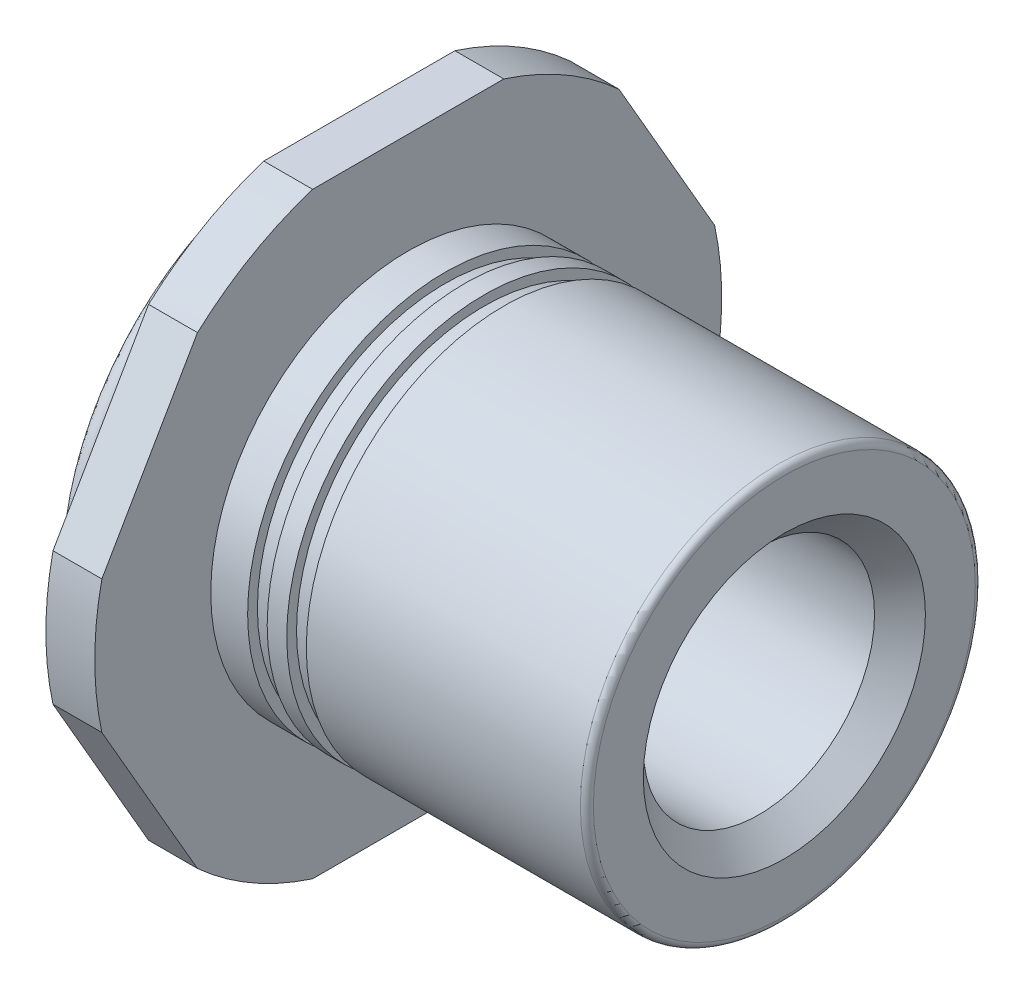
from build123d import *

# Parameters (mm, degrees)
BOSS_EXTRUDE1_DEPTH      = 0.52
M2_CLEARANCE_HOLE1_D     = 2.459
M2_CLEARANCE_HOLE1_DEPTH = 5.04
CHAMFER1_SIZE            = 0.2705
FILLET1_R                = 0.069333333


with BuildPart() as part:
    # Sketch1 → Boss-Extrude1 (new body)
    with BuildSketch(Plane(origin=(-0.52, 0, 0), x_dir=(0, -1, 0), z_dir=(-1, 0, 0))):
        with BuildLine():
            Line((-3.175, 1.016495973), (-3.175, -1.016495973))
            ThreePointArc((-3.175, -1.016495973), (-2.88711219, -1.666875), (-2.467811335, -2.241382671))
            Line((-2.467811335, -2.241382671), (-0.707188665, -3.257878643))
            ThreePointArc((-0.707188665, -3.257878643), (0, -3.33375), (0.707188665, -3.257878643))
            Line((0.707188665, -3.257878643), (2.467811335, -2.241382671))
            ThreePointArc((2.467811335, -2.241382671), (2.88711219, -1.666875), (3.175, -1.016495973))
            Line((3.175, -1.016495973), (3.175, 1.016495973))
            ThreePointArc((3.175, 1.016495973), (2.88711219, 1.666875), (2.467811335, 2.241382671))
            Line((2.467811335, 2.241382671), (0.707188665, 3.257878643))
            ThreePointArc((0.707188665, 3.257878643), (0, 3.33375), (-0.707188665, 3.257878643))
            Line((-0.707188665, 3.257878643), (-2.467811335, 2.241382671))
            ThreePointArc((-2.467811335, 2.241382671), (-2.88711219, 1.666875), (-3.175, 1.016495973))
        make_face()
    extrude(amount=-BOSS_EXTRUDE1_DEPTH)

    # Sketch2 → Revolve1 (revolve)
    with BuildSketch(Plane(origin=(0, 0, 0), x_dir=(-1, 0, 0), z_dir=(0, 0, -1))):
        with BuildLine():
            Line((0.52, 2.495411544), (0.52, 0))
            Line((0.52, 0), (1.04, 0))
            Line((1.04, 0), (1.04, 2.591))
            add(Edge.make_bspline(
                [(0.862460895, 2.664539105), (0.87069167, 2.672769881), (0.880457009, 2.679693108), (0.890948238, 2.684735472), (0.901439467, 2.689777836), (0.912945949, 2.693078411), (0.924514825, 2.694363876), (0.936083702, 2.69564934), (0.948034058, 2.694955148), (0.959376279, 2.692338786), (0.9707185, 2.689722424), (0.981765419, 2.68511173), (0.991602235, 2.678888517), (1.001439051, 2.672665304), (1.010337076, 2.664657929), (1.017559461, 2.655529485), (1.024781845, 2.646401041), (1.030527791, 2.635899755), (1.034321475, 2.624895242), (1.038055125, 2.614064874), (1.04, 2.602455872), (1.04, 2.591)],
                knots=[0, 0, 0, 0, 3.492e-05, 3.492e-05, 3.492e-05, 6.984e-05, 6.984e-05, 6.984e-05, 0.000104761, 0.000104761, 0.000104761, 0.000139681, 0.000139681, 0.000139681, 0.000174601, 0.000174601, 0.000174601, 0.000209521, 0.000209521, 0.000209521, 0.000243873, 0.000243873, 0.000243873, 0.000243873], degree=3))
            Line((0.862460895, 2.664539105), (0.693333333, 2.495411544))
            Line((0.693333333, 2.495411544), (0.52, 2.495411544))
        make_face()
    revolve(axis=Axis((-0.52, 0, 0), (-1, 0, 0)))

    # Sketch3 → Revolve2 (revolve)
    with BuildSketch(Plane(origin=(0, 0, 0), x_dir=(-1, 0, 0), z_dir=(0, 0, -1))):
        Polygon((-4, 2.1), (-4, 0), (0, 0), (0, 2.1), (-0.392, 2.1), (-0.392, 1.996), (-0.6, 1.996), (-0.6, 2.1), (-0.808, 2.1), (-0.808, 1.996), (-1.016, 1.996), (-1.016, 2.1), align=None)
    revolve(axis=Axis((4, 0, 0), (-1, 0, 0)))

    # M2 Clearance Hole1
    with Locations(Plane.ZY.offset(1.04)):
        with Locations((0, 0)):
            Hole(M2_CLEARANCE_HOLE1_D / 2, depth=M2_CLEARANCE_HOLE1_DEPTH)

    # Chamfer1
    chamfer1_edges = [part.edges().sort_by_distance(p)[0] for p in [
        (-1.04, 0, 1.2295),
        (4, 0, 1.2295),
    ]]
    chamfer(chamfer1_edges, length=CHAMFER1_SIZE)

    # Fillet1
    fillet1_edges = [part.edges().sort_by_distance(p)[0] for p in [
        (4, -2.1, 0),
    ]]
    fillet(fillet1_edges, radius=FILLET1_R)


solid = part.part
